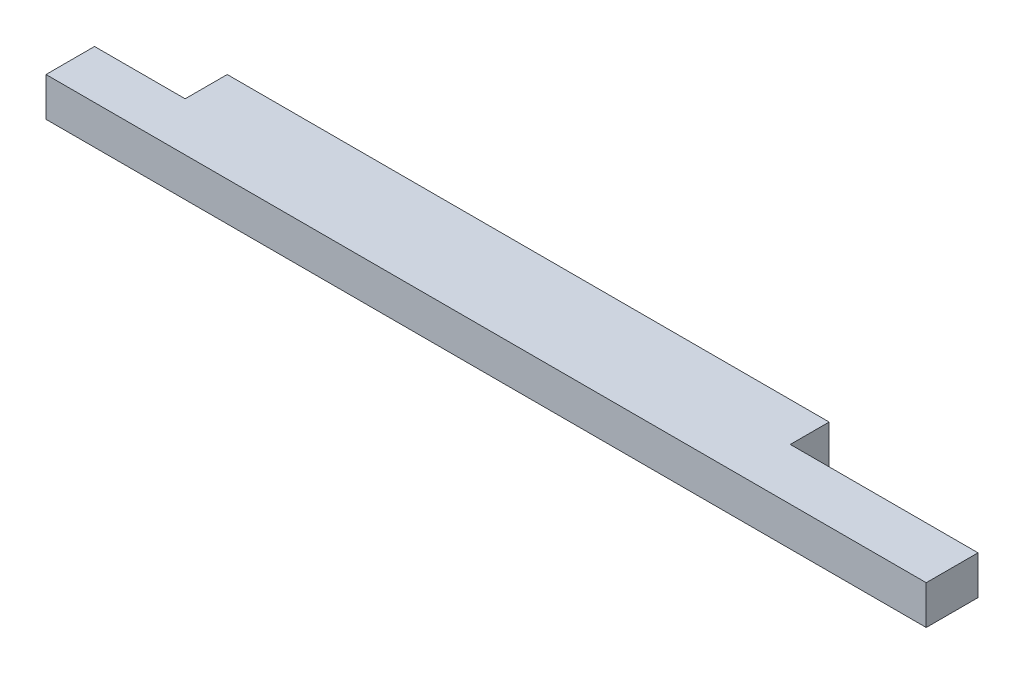
from build123d import *

# Parameters (mm, degrees)
SKETCH1_W           = 863.6
SKETCH1_H           = 88.9
BOSS_EXTRUDE1_DEPTH = 38.1
SKETCH3_W           = 184.15
SKETCH3_H           = 38.1
CUT_EXTRUDE1_DEPTH  = 39.1
SKETCH4_W           = 88.9
SKETCH4_H           = 41.275
CUT_EXTRUDE2_DEPTH  = 39.1


with BuildPart() as part:
    # Sketch1 → Boss-Extrude1 (new body)
    with BuildSketch(Plane(origin=(0, 0, 0), x_dir=(1, 0, 0), z_dir=(0, 1, 0))):
        with Locations((431.8, 44.45)):
            Rectangle(SKETCH1_W, SKETCH1_H)
    extrude(amount=BOSS_EXTRUDE1_DEPTH)

    # Sketch3 → Cut-Extrude1 (cut, through all)
    with BuildSketch(Plane(origin=(0, 38.1, 0), x_dir=(1, 0, 0), z_dir=(0, 1, 0))):
        with Locations((771.525, 69.85)):
            Rectangle(SKETCH3_W, SKETCH3_H)
    extrude(amount=-CUT_EXTRUDE1_DEPTH, mode=Mode.SUBTRACT)

    # Sketch4 → Cut-Extrude2 (cut, through all)
    with BuildSketch(Plane(origin=(0, 38.1, 0), x_dir=(1, 0, 0), z_dir=(0, 1, 0))):
        with Locations((44.45, 68.2625)):
            Rectangle(SKETCH4_W, SKETCH4_H)
    extrude(amount=-CUT_EXTRUDE2_DEPTH, mode=Mode.SUBTRACT)


solid = part.part
